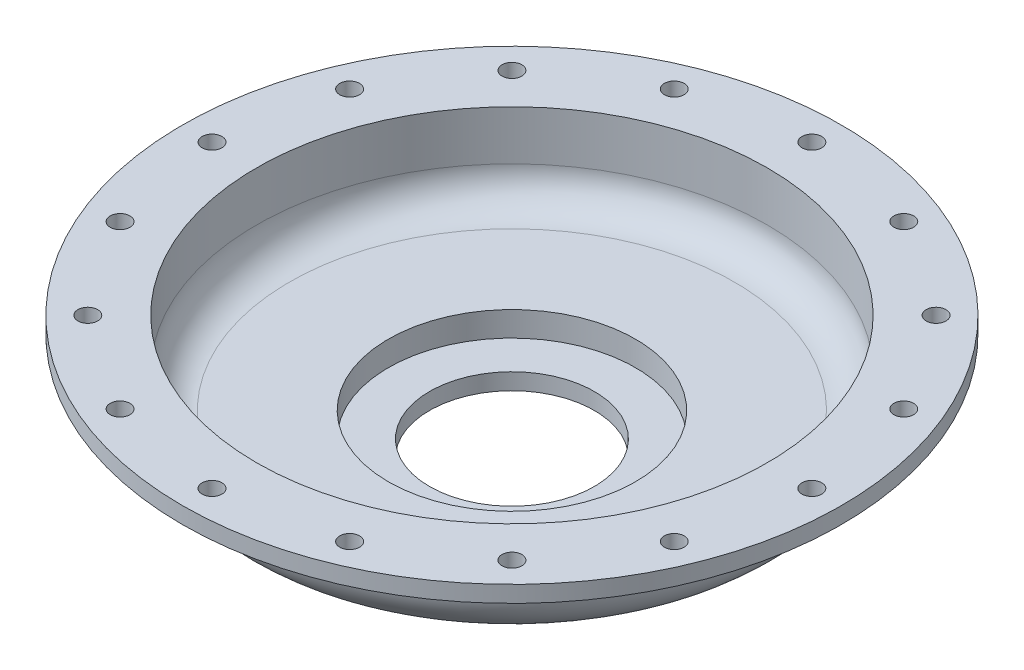
from build123d import *

# Parameters (mm, degrees)
SKETCH2_R               = 50
BOSS_EXTRUDE2_DEPTH     = 75
SKETCH3_R               = 200
SKETCH3_R_2             = 165
SKETCH3_R_3             = 6
BOSS_EXTRUDE8_DEPTH     = 10
SKETCH8_R               = 165
BOSS_EXTRUDE9_DEPTH     = 60
FILLET2_R               = 30
SKETCH12_R              = 85
BOSS_EXTRUDE11_DEPTH    = 15
SKETCH13_R              = 50
CUT_EXTRUDE4_DEPTH      = 293.617497768
CUT_EXTRUDE4_DEPTH_BACK = 293.617497768
SHELL12_T               = -10
SKETCH15_R              = 155
CUT_EXTRUDE7_DEPTH      = 10


with BuildPart() as part:
    # Sketch2 → Boss-Extrude2 (new body)
    with BuildSketch(Plane(origin=(0, 0, 0), x_dir=(1, 0, 0), z_dir=(0, 1, 0))):
        with Locations(Location((0, 0, 0), (0, 0, 270))):
            Circle(SKETCH2_R)
    extrude(amount=BOSS_EXTRUDE2_DEPTH)



with BuildPart() as body_2:
    # Sketch3 → Boss-Extrude8 (new body)
    with BuildSketch(Plane(origin=(0, 75, 0), x_dir=(1, 0, 0), z_dir=(0, 1, 0))):
        with Locations(Location((0, 0, 0), (0, 0, 270))):
            Circle(SKETCH3_R)
        with Locations(Location((0, 0, 0), (0, 0, 270))):
            Circle(SKETCH3_R_2, mode=Mode.SUBTRACT)
        with Locations(Location((0, 182, 0), (0, 0, 270))):
            Circle(SKETCH3_R_3, mode=Mode.SUBTRACT)
        with Locations(Location((69.64838469, 168.146074917, 0), (0, 0, 270))):
            Circle(SKETCH3_R_3, mode=Mode.SUBTRACT)
        with Locations(Location((128.693434176, 128.693434176, 0), (0, 0, 270))):
            Circle(SKETCH3_R_3, mode=Mode.SUBTRACT)
        with Locations(Location((168.146074917, 69.64838469, 0), (0, 0, 270))):
            Circle(SKETCH3_R_3, mode=Mode.SUBTRACT)
        with Locations(Location((182, 0, 0), (0, 0, 270))):
            Circle(SKETCH3_R_3, mode=Mode.SUBTRACT)
        with Locations(Location((168.146074917, -69.64838469, 0), (0, 0, 270))):
            Circle(SKETCH3_R_3, mode=Mode.SUBTRACT)
        with Locations(Location((128.693434176, -128.693434176, 0), (0, 0, 270))):
            Circle(SKETCH3_R_3, mode=Mode.SUBTRACT)
        with Locations(Location((69.64838469, -168.146074917, 0), (0, 0, 270))):
            Circle(SKETCH3_R_3, mode=Mode.SUBTRACT)
        with Locations(Location((0, -182, 0), (0, 0, 270))):
            Circle(SKETCH3_R_3, mode=Mode.SUBTRACT)
        with Locations(Location((-69.64838469, -168.146074917, 0), (0, 0, 270))):
            Circle(SKETCH3_R_3, mode=Mode.SUBTRACT)
        with Locations(Location((-128.693434176, -128.693434176, 0), (0, 0, 270))):
            Circle(SKETCH3_R_3, mode=Mode.SUBTRACT)
        with Locations(Location((-168.146074917, -69.64838469, 0), (0, 0, 270))):
            Circle(SKETCH3_R_3, mode=Mode.SUBTRACT)
        with Locations(Location((-182, 0, 0), (0, 0, 270))):
            Circle(SKETCH3_R_3, mode=Mode.SUBTRACT)
        with Locations(Location((-168.146074917, 69.64838469, 0), (0, 0, 270))):
            Circle(SKETCH3_R_3, mode=Mode.SUBTRACT)
        with Locations(Location((-128.693434176, 128.693434176, 0), (0, 0, 270))):
            Circle(SKETCH3_R_3, mode=Mode.SUBTRACT)
        with Locations(Location((-69.64838469, 168.146074917, 0), (0, 0, 270))):
            Circle(SKETCH3_R_3, mode=Mode.SUBTRACT)
    extrude(amount=-BOSS_EXTRUDE8_DEPTH)


with BuildPart() as part_1:
    add(part.part)

    add(body_2.part)  # Boss-Extrude9 merges body 2
    # Sketch8 → Boss-Extrude9 (add)
    with BuildSketch(Plane(origin=(0, 75, 0), x_dir=(1, 0, 0), z_dir=(0, 1, 0))):
        with Locations(Location((0, 0, 0), (0, 0, 270))):
            Circle(SKETCH8_R)
    extrude(amount=-BOSS_EXTRUDE9_DEPTH)

    # Fillet2
    fillet2_edges = [part_1.edges().sort_by_distance(p)[0] for p in [
        (0, 15, -165),
    ]]
    fillet(fillet2_edges, radius=FILLET2_R)

    # Sketch12 → Boss-Extrude11 (add)
    with BuildSketch(Plane.XZ.offset(-15)):
        with Locations(Location((0, 0, 0), (0, 0, 90))):
            Circle(SKETCH12_R)
    extrude(amount=BOSS_EXTRUDE11_DEPTH)

    # Sketch13 → Cut-Extrude4 (cut, two sides)
    with BuildSketch(Plane.XZ) as cut_extrude4_sk:
        with Locations(Location((0, 0, 0), (0, 0, 270))):
            Circle(SKETCH13_R)
    extrude(amount=CUT_EXTRUDE4_DEPTH, mode=Mode.SUBTRACT)
    extrude(cut_extrude4_sk.sketch, amount=-CUT_EXTRUDE4_DEPTH_BACK, mode=Mode.SUBTRACT)

    # Shell12
    shell12_openings = [part_1.faces().sort_by_distance(p)[0] for p in [
        (0, 37.5, 50),
    ]]
    offset(amount=SHELL12_T, openings=shell12_openings, kind=Kind.INTERSECTION)

    # Sketch15 → Cut-Extrude7 (cut)
    with BuildSketch(Plane(origin=(0, 75, 0), x_dir=(1, 0, 0), z_dir=(0, 1, 0))):
        with Locations(Location((0, 0, 0), (0, 0, 270))):
            Circle(SKETCH15_R)
    extrude(amount=-CUT_EXTRUDE7_DEPTH, mode=Mode.SUBTRACT)


solid = part_1.part
